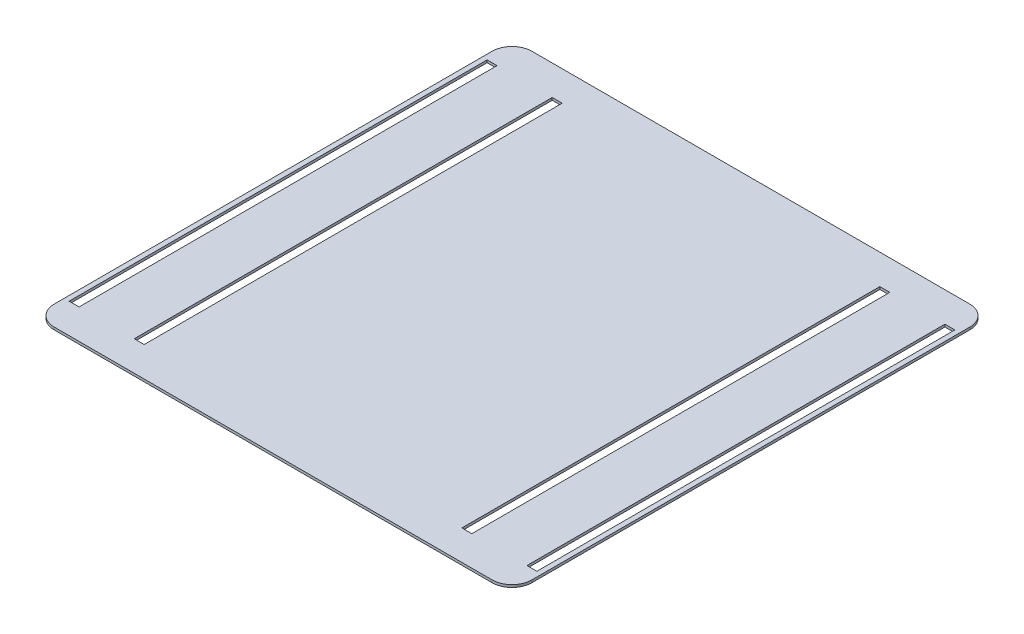
from build123d import *

# Parameters (mm, degrees)
SKETCH1_W           = 609.6
SKETCH1_H           = 609.6
BOSS_EXTRUDE1_DEPTH = 3.175
FILLET1_R           = 25.4
SKETCH2_W           = 12.7
SKETCH2_H           = 533.4
CUT_EXTRUDE1_DEPTH  = 3.175


with BuildPart() as part:
    # Sketch1 → Boss-Extrude1 (new body)
    with BuildSketch(Plane(origin=(0, 0, 0), x_dir=(1, 0, 0), z_dir=(0, 1, 0))):
        Rectangle(SKETCH1_W, SKETCH1_H)
    extrude(amount=BOSS_EXTRUDE1_DEPTH)

    # Fillet1
    fillet1_edges = [part.edges().sort_by_distance(p)[0] for p in [
        (304.8, 1.5875, 304.8),
        (-304.8, 1.5875, 304.8),
        (-304.8, 1.5875, -304.8),
        (304.8, 1.5875, -304.8),
    ]]
    fillet(fillet1_edges, radius=FILLET1_R)

    # Sketch2 → Cut-Extrude1 (cut)
    with BuildSketch(Plane(origin=(0, 3.175, 0), x_dir=(1, 0, 0), z_dir=(0, 1, 0))):
        with Locations((209.042, 0)):
            Rectangle(SKETCH2_W, SKETCH2_H)
        with Locations((-209.042, 0)):
            Rectangle(SKETCH2_W, SKETCH2_H)
        with Locations((-292.1, 0)):
            Rectangle(SKETCH2_W, SKETCH2_H)
        with Locations((292.1, 0)):
            Rectangle(SKETCH2_W, SKETCH2_H)
    extrude(amount=-CUT_EXTRUDE1_DEPTH, mode=Mode.SUBTRACT)


solid = part.part
